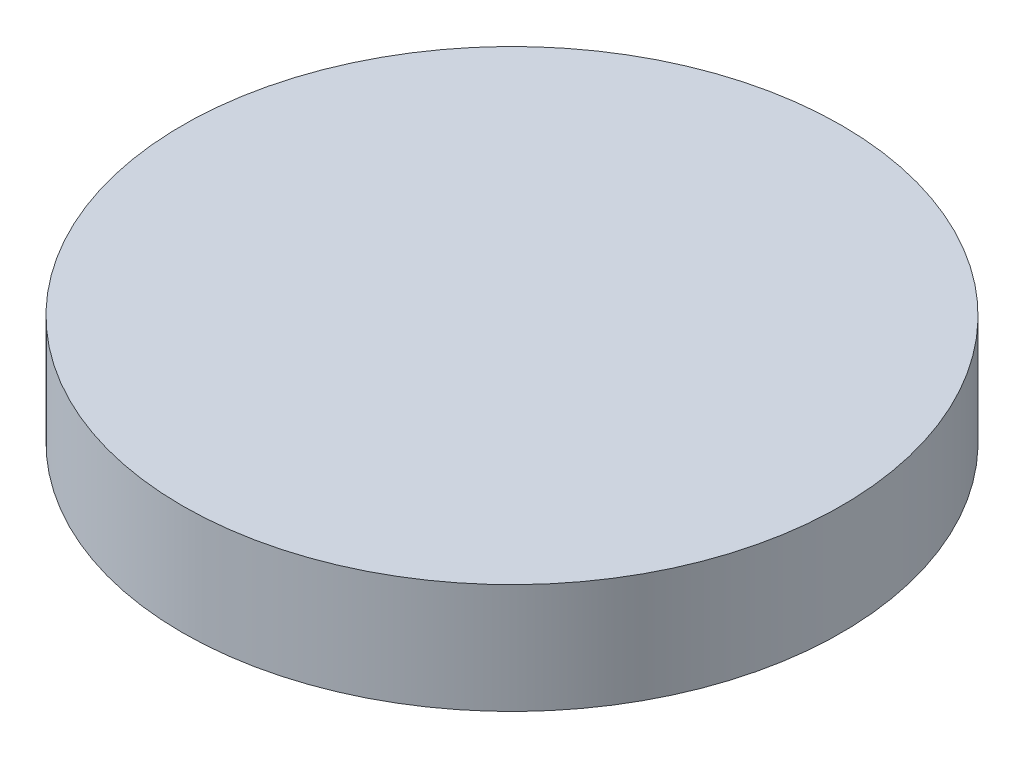
from build123d import *

# Parameters (mm, degrees)
SKETCH1_R           = 19.05
BOSS_EXTRUDE1_DEPTH = 6.35


with BuildPart() as part:
    # Sketch1 → Boss-Extrude1 (new body)
    with BuildSketch(Plane(origin=(0, 0, 0), x_dir=(1, 0, 0), z_dir=(0, 1, 0))):
        with Locations((-47.708783594, -19.327011731)):
            Circle(SKETCH1_R)
    extrude(amount=BOSS_EXTRUDE1_DEPTH)


solid = part.part
